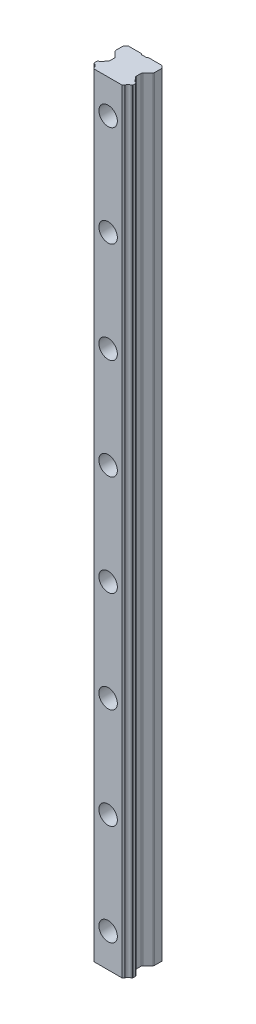
from build123d import *

# Parameters (mm, degrees)
DODANIE_WYCI_GNI_CIE1_DEPTH = 460
WYTNIJ_WYCI_GNI_CIE1_DEPTH  = 461
SZKIC7_W                    = 5.5
SZKIC7_H                    = 0.01000001
SZKIC8_W                    = 5.5
SZKIC8_H                    = 0.01000001
SZKIC9_W                    = 5.5
SZKIC9_H                    = 0.01000001
SZKIC10_W                   = 5.5
SZKIC10_H                   = 0.01000001
SZKIC11_W                   = 5.5
SZKIC11_H                   = 0.01000001
SZKIC12_W                   = 5.5
SZKIC12_H                   = 0.01000001
SZKIC13_W                   = 5.5
SZKIC13_H                   = 0.01000001
SZKIC14_W                   = 5.5
SZKIC14_H                   = 0.01000001
SFAZOWANIE2_SIZE            = 1.52785882
SFAZOWANIE2_SIZE2           = 1.5207795
SFAZOWANIE4_SIZE            = 1.5207795
SFAZOWANIE4_SIZE2           = 1.52785882
ZAOKR_GLENIE1_R             = 0.499999854
ZAOKR_GLENIE2_R             = 0.999996936


with BuildPart() as part:
    # Szkic1 → Dodanie-wyciągnięcie1 (new body)
    with BuildSketch(Plane.XZ):
        with BuildLine():
            Line((-11.5, 6.269384953), (-11.5, 0))
            Line((-11.5, 0), (11.5, 0))
            Line((11.5, 0), (11.5, 6.269384953))
            Line((11.5, 6.269384953), (7.91556798, 9.879088917))
            Line((7.91556798, 9.879088917), (7.91556798, 13.52061035))
            Line((7.91556798, 13.52061035), (8.93872733, 14.5437697))
            ThreePointArc((8.93872733, 14.5437697), (9.052804678, 14.638756238), (9.13396618, 14.76304982))
            ThreePointArc((9.13396618, 14.76304982), (9.83021824, 15.989534483), (11.095172541, 16.613170738))
            Line((11.095172541, 16.613170738), (11.5, 17.01799817))
            Line((11.5, 17.01799817), (11.5, 18.83162682))
            Line((11.5, 18.83162682), (11.093547074, 19.238079746))
            ThreePointArc((11.093547074, 19.238079746), (9.804732951, 19.879523761), (9.11483221, 21.14306214))
            ThreePointArc((9.11483221, 21.14306214), (9.084093131, 21.201069918), (9.04575086, 21.25435841))
            Line((9.04575086, 21.25435841), (8.30010926, 22.00000001))
            Line((8.30010926, 22.00000001), (-8.30010926, 22.00000001))
            Line((-8.30010926, 22.00000001), (-9.04575086, 21.25435841))
            ThreePointArc((-9.04575086, 21.25435841), (-9.08409312, 21.20106991), (-9.11483221, 21.14306214))
            ThreePointArc((-9.11483221, 21.14306214), (-9.804732946, 19.879523757), (-11.093547072, 19.238079748))
            Line((-11.093547072, 19.238079748), (-11.5, 18.83162682))
            Line((-11.5, 18.83162682), (-11.5, 17.01799817))
            Line((-11.5, 17.01799817), (-11.095172541, 16.613170738))
            ThreePointArc((-11.095172541, 16.613170738), (-9.83021824, 15.989534483), (-9.13396618, 14.76304982))
            ThreePointArc((-9.13396618, 14.76304982), (-9.052804683, 14.638756234), (-8.93872733, 14.5437697))
            Line((-8.93872733, 14.5437697), (-7.91556798, 13.52061035))
            Line((-7.91556798, 13.52061035), (-7.91556798, 9.879088917))
            Line((-7.91556798, 9.879088917), (-11.5, 6.269384953))
        make_face()
    extrude(amount=-DODANIE_WYCI_GNI_CIE1_DEPTH)

    # Szkic2 → Wytnij-wyciągnięcie1 (cut, through all)
    with BuildSketch(Plane(origin=(0, 460, 0), x_dir=(-1, 0, 0), z_dir=(0, 1, 0))):
        Polygon((-2.10671821, 0), (2.10671821, 0), (1.58064429, 0.52607392), (-1.58064429, 0.52607392), align=None)
    extrude(amount=-WYTNIJ_WYCI_GNI_CIE1_DEPTH, mode=Mode.SUBTRACT)

    # Szkic7 → Wycięcie-obrót1 (revolve, cut)
    with BuildSketch(Plane.XZ.offset(-20)):
        with Locations((2.75, 21.995000005)):
            Rectangle(SZKIC7_W, SZKIC7_H)
    revolve(axis=Axis((0, 20, 22.00000001), (0, 0, -1)), mode=Mode.SUBTRACT)

    # Szkic8 → Wycięcie-obrót2 (revolve, cut)
    with BuildSketch(Plane.XZ.offset(-80)):
        with Locations((2.75, 21.995000005)):
            Rectangle(SZKIC8_W, SZKIC8_H)
    revolve(axis=Axis((0, 80, 22.00000001), (0, 0, -1)), mode=Mode.SUBTRACT)

    # Szkic9 → Wycięcie-obrót3 (revolve, cut)
    with BuildSketch(Plane.XZ.offset(-140)):
        with Locations((2.75, 21.995000005)):
            Rectangle(SZKIC9_W, SZKIC9_H)
    revolve(axis=Axis((0, 140, 22.00000001), (0, 0, -1)), mode=Mode.SUBTRACT)

    # Szkic10 → Wycięcie-obrót4 (revolve, cut)
    with BuildSketch(Plane.XZ.offset(-200)):
        with Locations((2.75, 21.995000005)):
            Rectangle(SZKIC10_W, SZKIC10_H)
    revolve(axis=Axis((0, 200, 22.00000001), (0, 0, -1)), mode=Mode.SUBTRACT)

    # Szkic11 → Wycięcie-obrót5 (revolve, cut)
    with BuildSketch(Plane.XZ.offset(-260)):
        with Locations((2.75, 21.995000005)):
            Rectangle(SZKIC11_W, SZKIC11_H)
    revolve(axis=Axis((0, 260, 22.00000001), (0, 0, -1)), mode=Mode.SUBTRACT)

    # Szkic12 → Wycięcie-obrót6 (revolve, cut)
    with BuildSketch(Plane.XZ.offset(-320)):
        with Locations((2.75, 21.995000005)):
            Rectangle(SZKIC12_W, SZKIC12_H)
    revolve(axis=Axis((0, 320, 22.00000001), (0, 0, -1)), mode=Mode.SUBTRACT)

    # Szkic13 → Wycięcie-obrót7 (revolve, cut)
    with BuildSketch(Plane.XZ.offset(-380)):
        with Locations((2.75, 21.995000005)):
            Rectangle(SZKIC13_W, SZKIC13_H)
    revolve(axis=Axis((0, 380, 22.00000001), (0, 0, -1)), mode=Mode.SUBTRACT)

    # Szkic14 → Wycięcie-obrót8 (revolve, cut)
    with BuildSketch(Plane.XZ.offset(-440)):
        with Locations((2.75, 21.995000005)):
            Rectangle(SZKIC14_W, SZKIC14_H)
    revolve(axis=Axis((0, 440, 22.00000001), (0, 0, -1)), mode=Mode.SUBTRACT)

    # Szkic24 → Wycięcie-obrót18 (revolve, cut)
    with BuildSketch(Plane.XZ.offset(-20)):
        Polygon((5.5, 22), (0, 22), (0, 0), (3.5, 0), (3.5, 13), (5.5, 13), align=None)
    revolve(axis=Axis((0, 20, 22), (0, 0, -1)), mode=Mode.SUBTRACT)

    # Szkic25 → Wycięcie-obrót19 (revolve, cut)
    with BuildSketch(Plane.XZ.offset(-80)):
        Polygon((5.5, 22), (0, 22), (0, 0), (3.5, 0), (3.5, 13), (5.5, 13), align=None)
    revolve(axis=Axis((0, 80, 22), (0, 0, -1)), mode=Mode.SUBTRACT)

    # Szkic26 → Wycięcie-obrót20 (revolve, cut)
    with BuildSketch(Plane.XZ.offset(-140)):
        Polygon((5.5, 22), (0, 22), (0, 0), (3.5, 0), (3.5, 13), (5.5, 13), align=None)
    revolve(axis=Axis((0, 140, 22), (0, 0, -1)), mode=Mode.SUBTRACT)

    # Szkic27 → Wycięcie-obrót21 (revolve, cut)
    with BuildSketch(Plane.XZ.offset(-200)):
        Polygon((5.5, 22), (0, 22), (0, 0), (3.5, 0), (3.5, 13), (5.5, 13), align=None)
    revolve(axis=Axis((0, 200, 22), (0, 0, -1)), mode=Mode.SUBTRACT)

    # Szkic28 → Wycięcie-obrót22 (revolve, cut)
    with BuildSketch(Plane.XZ.offset(-260)):
        Polygon((5.5, 22), (0, 22), (0, 0), (3.5, 0), (3.5, 13), (5.5, 13), align=None)
    revolve(axis=Axis((0, 260, 22), (0, 0, -1)), mode=Mode.SUBTRACT)

    # Szkic29 → Wycięcie-obrót23 (revolve, cut)
    with BuildSketch(Plane.XZ.offset(-320)):
        Polygon((5.5, 22), (0, 22), (0, 0), (3.5, 0), (3.5, 13), (5.5, 13), align=None)
    revolve(axis=Axis((0, 320, 22), (0, 0, -1)), mode=Mode.SUBTRACT)

    # Szkic30 → Wycięcie-obrót24 (revolve, cut)
    with BuildSketch(Plane.XZ.offset(-380)):
        Polygon((5.5, 22), (0, 22), (0, 0), (3.5, 0), (3.5, 13), (5.5, 13), align=None)
    revolve(axis=Axis((0, 380, 22), (0, 0, -1)), mode=Mode.SUBTRACT)

    # Szkic31 → Wycięcie-obrót25 (revolve, cut)
    with BuildSketch(Plane.XZ.offset(-440)):
        Polygon((5.5, 22), (0, 22), (0, 0), (3.5, 0), (3.5, 13), (5.5, 13), align=None)
    revolve(axis=Axis((0, 440, 22), (0, 0, -1)), mode=Mode.SUBTRACT)

    # Sfazowanie2
    sfazowanie2_edges = [part.edges().sort_by_distance(p)[0] for p in [
        (11.5, 230, 0),
    ]]
    sfazowanie2_side = [part.faces().sort_by_distance(p)[0] for p in [
        (11.5, 230, 3.134692476),
    ]]
    chamfer(sfazowanie2_edges, length=SFAZOWANIE2_SIZE, length2=SFAZOWANIE2_SIZE2, reference=sfazowanie2_side[0])

    # Sfazowanie4
    sfazowanie4_edges = [part.edges().sort_by_distance(p)[0] for p in [
        (-11.5, 230, 0),
    ]]
    sfazowanie4_side = [part.faces().sort_by_distance(p)[0] for p in [
        (-6.845378829, 230, 0),
    ]]
    chamfer(sfazowanie4_edges, length=SFAZOWANIE4_SIZE, length2=SFAZOWANIE4_SIZE2, reference=sfazowanie4_side[0])

    # Zaokrąglenie1
    zaokr_glenie1_edges = [part.edges().sort_by_distance(p)[0] for p in [
        (-11.095172541, 230, 16.613170738),
        (-11.5, 230, 17.01799817),
        (-11.5, 230, 18.83162682),
        (-11.093547072, 230, 19.238079748),
        (11.093547074, 230, 19.238079746),
        (11.5, 230, 18.83162682),
        (11.5, 230, 17.01799817),
        (11.095172541, 230, 16.613170738),
    ]]
    fillet(zaokr_glenie1_edges, radius=ZAOKR_GLENIE1_R)

    # Zaokrąglenie2
    zaokr_glenie2_edges = [part.edges().sort_by_distance(p)[0] for p in [
        (-7.91556798, 230, 9.879088917),
        (-7.91556798, 230, 13.52061035),
        (7.91556798, 230, 13.52061035),
        (7.91556798, 230, 9.879088917),
        (11.5, 230, 6.269384953),
        (-11.5, 230, 6.269384953),
    ]]
    fillet(zaokr_glenie2_edges, radius=ZAOKR_GLENIE2_R)


solid = part.part
